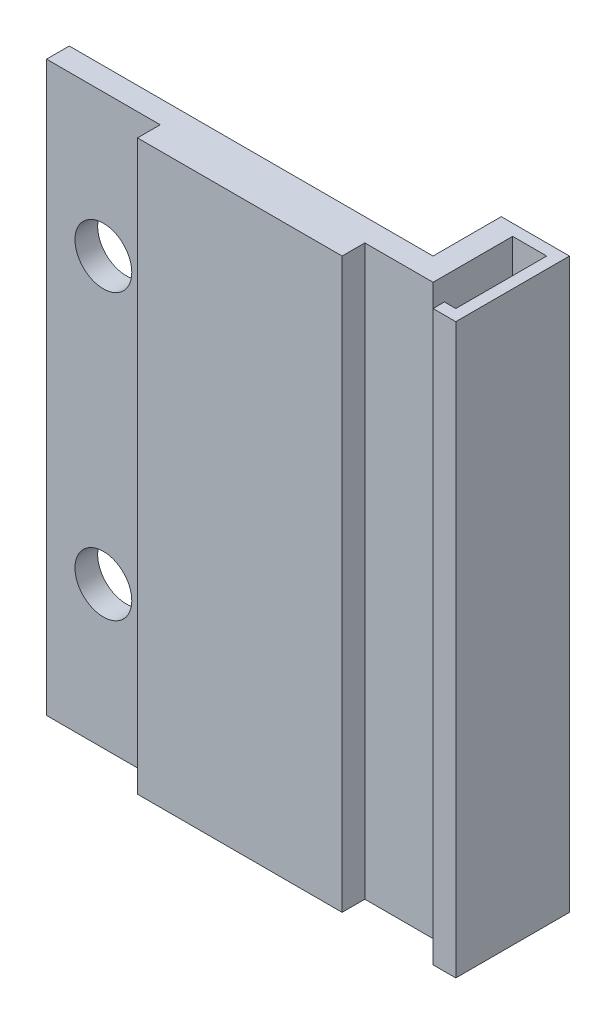
from build123d import *

# Parameters (mm, degrees)
ESQUISSE1_W             = 10
ESQUISSE1_H             = 50
ESQUISSE1_R             = 2.5
ESQUISSE1_W_2           = 2
BOSS_EXTRU_1_DEPTH      = 2
ESQUISSE2_W             = 2
ESQUISSE2_H             = 50
BOSS_EXTRU_2_DEPTH      = 2
ESQUISSE3_W             = 4
ESQUISSE3_H             = 50
BOSS_EXTRU_3_DEPTH      = 22
ESQUISSE4_W             = 2
ESQUISSE4_H             = 50
BOSS_EXTRU_4_DEPTH      = 6
ESQUISSE5_W             = 2
ESQUISSE5_H             = 50
ENL_V_MAT_EXTRU_1_DEPTH = 6
ESQUISSE6_W             = 1
ESQUISSE6_H             = 50
BOSS_EXTRU_5_DEPTH      = 4
ESQUISSE7_W             = 1
ESQUISSE7_H             = 50
BOSS_EXTRU_6_DEPTH      = 9
ESQUISSE8_W             = 1
ESQUISSE8_H             = 50
BOSS_EXTRU_7_DEPTH      = 1


with BuildPart() as part:
    # Esquisse1 → Boss.-Extru.1 (new body)
    with BuildSketch(Plane.XY):
        with Locations((5, 25)):
            Rectangle(ESQUISSE1_W, ESQUISSE1_H)
        with Locations((5, 12.5)):
            Circle(ESQUISSE1_R, mode=Mode.SUBTRACT)
        with Locations((5, 37.5)):
            Circle(ESQUISSE1_R, mode=Mode.SUBTRACT)
        with Locations((11, 25)):
            Rectangle(ESQUISSE1_W_2, ESQUISSE1_H)
    extrude(amount=BOSS_EXTRU_1_DEPTH)

    # Esquisse2 → Boss.-Extru.2 (add)
    with BuildSketch(Plane.XY.offset(2)):
        with Locations((11, 25)):
            Rectangle(ESQUISSE2_W, ESQUISSE2_H)
    extrude(amount=BOSS_EXTRU_2_DEPTH)

    # Esquisse3 → Boss.-Extru.3 (add)
    with BuildSketch(Plane(origin=(12, 0, 0), x_dir=(0, 0, -1), z_dir=(1, 0, 0))):
        with Locations((-2, 25)):
            Rectangle(ESQUISSE3_W, ESQUISSE3_H)
    extrude(amount=BOSS_EXTRU_3_DEPTH)

    # Esquisse4 → Boss.-Extru.4 (add)
    with BuildSketch(Plane(origin=(0, 0, 0), x_dir=(-1, 0, 0), z_dir=(0, 0, -1))):
        with Locations((-33, 25)):
            Rectangle(ESQUISSE4_W, ESQUISSE4_H)
    extrude(amount=BOSS_EXTRU_4_DEPTH)

    # Esquisse5 → Enlèv. mat.-Extru.1 (cut)
    with BuildSketch(Plane(origin=(34, 0, 0), x_dir=(0, 0, -1), z_dir=(1, 0, 0))):
        with Locations((-3, 25)):
            Rectangle(ESQUISSE5_W, ESQUISSE5_H)
    extrude(amount=-ENL_V_MAT_EXTRU_1_DEPTH, mode=Mode.SUBTRACT)

    # Esquisse6 → Boss.-Extru.5 (add)
    with BuildSketch(Plane(origin=(34, 0, 0), x_dir=(0, 0, -1), z_dir=(1, 0, 0))):
        with Locations((5.5, 25)):
            Rectangle(ESQUISSE6_W, ESQUISSE6_H)
    extrude(amount=BOSS_EXTRU_5_DEPTH)

    # Esquisse7 → Boss.-Extru.6 (add)
    with BuildSketch(Plane.XY.offset(-5)):
        with Locations((37.5, 25)):
            Rectangle(ESQUISSE7_W, ESQUISSE7_H)
    extrude(amount=BOSS_EXTRU_6_DEPTH)

    # Esquisse8 → Boss.-Extru.7 (add)
    with BuildSketch(Plane.ZY.offset(-37)):
        with Locations((3.5, 25)):
            Rectangle(ESQUISSE8_W, ESQUISSE8_H)
    extrude(amount=BOSS_EXTRU_7_DEPTH)


solid = part.part
